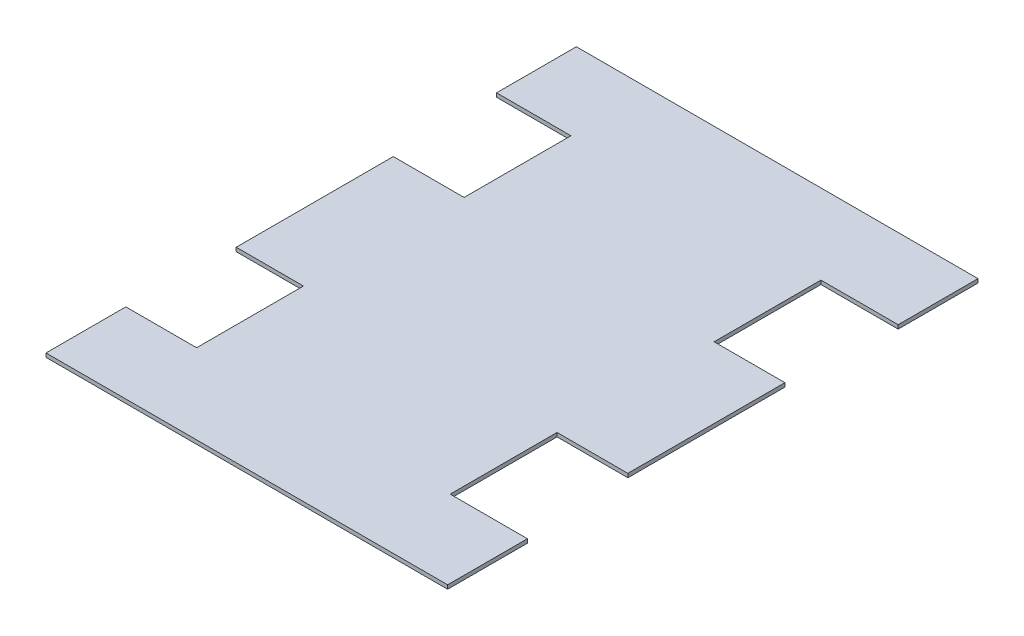
from build123d import *

# Parameters (mm, degrees)
BOSS_EXTRUDE1_DEPTH = 3


with BuildPart() as part:
    # Sketch1 → Boss-Extrude1 (new body)
    with BuildSketch(Plane(origin=(0, 0, 0), x_dir=(1, 0, 0), z_dir=(0, 1, 0))):
        Polygon((-27.024736932, 144.778970111), (-27.024736932, 206.778970111), (284.975263068, 206.778970111), (284.975263068, 144.778970111), (224.971702652, 144.778970111), (224.971702652, 61.778970111), (279.971702652, 61.778970111), (279.971702652, -60.221029889), (224.971702652, -60.221029889), (224.971702652, -143.221029889), (284.975263068, -143.221029889), (284.975263068, -205.221029889), (-27.024736932, -205.221029889), (-27.024736932, -143.221029889), (27.975263068, -143.221029889), (27.975263068, -60.221029889), (-24.243142, -60.221029889), (-24.243142, 61.778970111), (30.756858, 61.778970111), (30.756858, 144.778970111), align=None)
    extrude(amount=BOSS_EXTRUDE1_DEPTH)


solid = part.part
